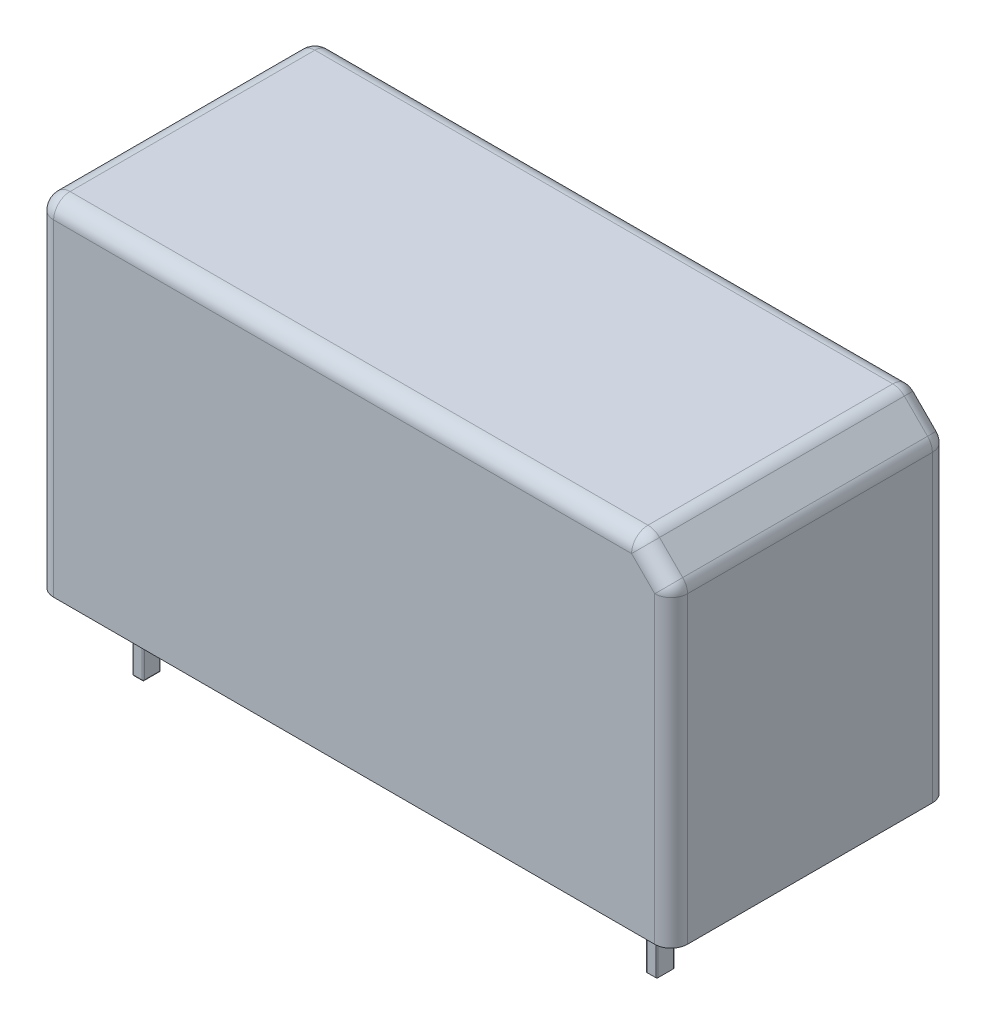
from build123d import *

# Parameters (mm, degrees)
SKETCH_1_W      = 29
SKETCH_1_H      = 12.7
EXTRUDE_1_DEPTH = 15.7
EXTRUDE_2_DEPTH = 3.5
FILLET_1_R      = 0.05
CHAMFER_1_SIZE  = 1.5
FILLET_2_R      = 0.75


with BuildPart() as part:
    # Эскиз1 → Бобышка-Вытянуть1 (new body)
    with BuildSketch(Plane(origin=(0, 0, 0), x_dir=(1, 0, 0), z_dir=(0, 1, 0))):
        Rectangle(SKETCH_1_W, SKETCH_1_H)
    extrude(amount=EXTRUDE_1_DEPTH)

    # Эскиз2 → Бобышка-Вытянуть2 (add)
    with BuildSketch(Plane.XZ):
        with BuildLine():
            Line((-12.3, 4.15), (-11.9, 4.15))
            ThreePointArc((-11.9, 4.15), (-11.864644661, 4.135355339), (-11.85, 4.1))
            Line((-11.85, 4.1), (-11.85, 3.4))
            ThreePointArc((-11.85, 3.4), (-11.864644661, 3.364644661), (-11.9, 3.35))
            Line((-11.9, 3.35), (-12.3, 3.35))
            ThreePointArc((-12.3, 3.35), (-12.335355339, 3.364644661), (-12.35, 3.4))
            Line((-12.35, 3.4), (-12.35, 4.1))
            ThreePointArc((-12.35, 4.1), (-12.335355339, 4.135355339), (-12.3, 4.15))
        make_face()
        with BuildLine():
            Line((7.65, -3.4), (7.65, -4.1))
            ThreePointArc((7.65, -4.1), (7.664644661, -4.135355339), (7.7, -4.15))
            Line((7.7, -4.15), (8.1, -4.15))
            ThreePointArc((8.1, -4.15), (8.135355339, -4.135355339), (8.15, -4.1))
            Line((8.15, -4.1), (8.15, -3.4))
            ThreePointArc((8.15, -3.4), (8.135355339, -3.364644661), (8.1, -3.35))
            Line((8.1, -3.35), (7.7, -3.35))
            ThreePointArc((7.7, -3.35), (7.664644661, -3.364644661), (7.65, -3.4))
        make_face()
        with BuildLine():
            Line((-12.35, -3.4), (-12.35, -4.1))
            ThreePointArc((-12.35, -4.1), (-12.335355339, -4.135355339), (-12.3, -4.15))
            Line((-12.3, -4.15), (-11.9, -4.15))
            ThreePointArc((-11.9, -4.15), (-11.864644661, -4.135355339), (-11.85, -4.1))
            Line((-11.85, -4.1), (-11.85, -3.4))
            ThreePointArc((-11.85, -3.4), (-11.864644661, -3.364644661), (-11.9, -3.35))
            Line((-11.9, -3.35), (-12.3, -3.35))
            ThreePointArc((-12.3, -3.35), (-12.335355339, -3.364644661), (-12.35, -3.4))
        make_face()
        with BuildLine():
            Line((11.2, 4.15), (11.6, 4.15))
            ThreePointArc((11.6, 4.15), (11.635355339, 4.135355339), (11.65, 4.1))
            Line((11.65, 4.1), (11.65, 3.4))
            ThreePointArc((11.65, 3.4), (11.635355339, 3.364644661), (11.6, 3.35))
            Line((11.6, 3.35), (11.2, 3.35))
            ThreePointArc((11.2, 3.35), (11.164644661, 3.364644661), (11.15, 3.4))
            Line((11.15, 3.4), (11.15, 4.1))
            ThreePointArc((11.15, 4.1), (11.164644661, 4.135355339), (11.2, 4.15))
        make_face()
    extrude(amount=EXTRUDE_2_DEPTH)

    # Скругление1
    fillet_1_edges = [part.edges().sort_by_distance(p)[0] for p in [
        (-12.335355339, -3.5, 3.364644661),
        (-12.1, -3.5, 3.35),
        (-11.864644661, -3.5, 3.364644661),
        (-11.85, -3.5, 3.75),
        (-11.864644661, -3.5, 4.135355339),
        (-12.1, -3.5, 4.15),
        (-12.335355339, -3.5, 4.135355339),
        (-12.35, -3.5, 3.75),
        (7.664644661, -3.5, -4.135355339),
        (7.9, -3.5, -4.15),
        (8.135355339, -3.5, -4.135355339),
        (8.15, -3.5, -3.75),
        (8.135355339, -3.5, -3.364644661),
        (7.9, -3.5, -3.35),
        (7.664644661, -3.5, -3.364644661),
        (7.65, -3.5, -3.75),
        (-12.335355339, -3.5, -4.135355339),
        (-12.1, -3.5, -4.15),
        (-11.864644661, -3.5, -4.135355339),
        (-11.85, -3.5, -3.75),
        (-11.864644661, -3.5, -3.364644661),
        (-12.1, -3.5, -3.35),
        (-12.335355339, -3.5, -3.364644661),
        (-12.35, -3.5, -3.75),
    ]]
    fillet(fillet_1_edges, radius=FILLET_1_R)

    # Фаска1
    chamfer_1_edges = [part.edges().sort_by_distance(p)[0] for p in [
        (14.5, 15.7, 0),
    ]]
    chamfer(chamfer_1_edges, length=CHAMFER_1_SIZE)

    # Скругление2
    fillet_2_edges = [part.edges().sort_by_distance(p)[0] for p in [
        (-14.5, 15.7, 0),
        (-0.75, 15.7, 6.35),
        (-0.75, 15.7, -6.35),
        (13, 15.7, 0),
        (14.5, 7.1, -6.35),
        (13.75, 14.95, -6.35),
        (14.5, 7.1, 6.35),
        (14.5, 14.2, 0),
        (13.75, 14.95, 6.35),
        (-14.5, 7.85, 6.35),
        (-14.5, 7.85, -6.35),
    ]]
    fillet(fillet_2_edges, radius=FILLET_2_R)


solid = part.part
